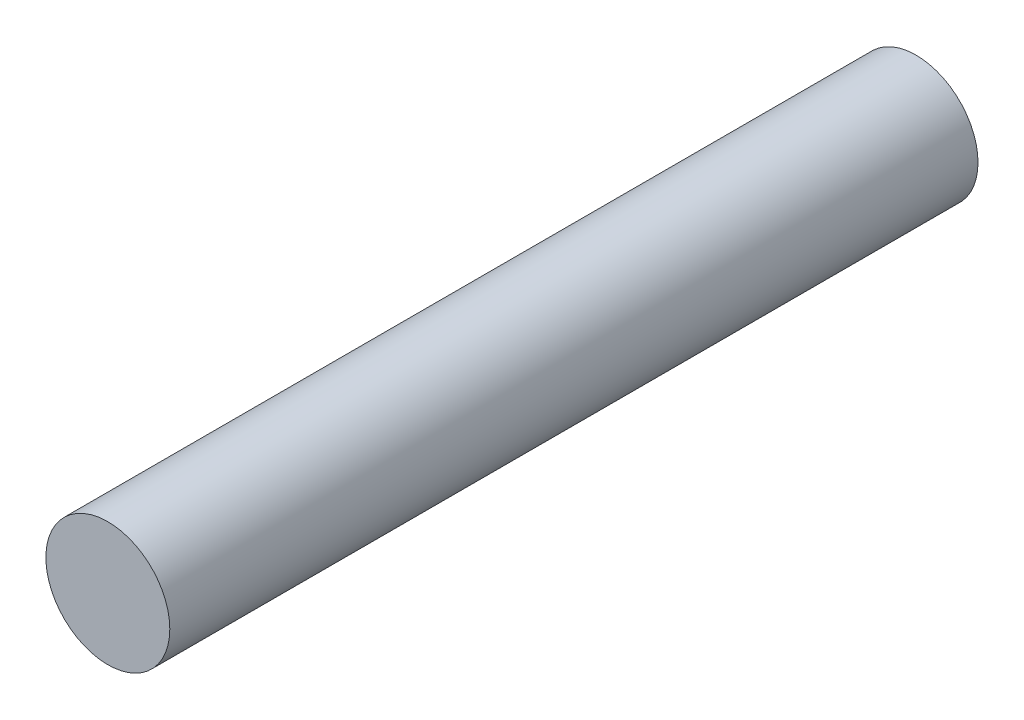
from build123d import *

# Parameters (mm, degrees)
SKETCH1_R           = 1.4605
BOSS_EXTRUDE1_DEPTH = 19.05


with BuildPart() as part:
    # Sketch1 → Boss-Extrude1 (new body)
    with BuildSketch(Plane.XY):
        Circle(SKETCH1_R)
    extrude(amount=BOSS_EXTRUDE1_DEPTH)


solid = part.part
